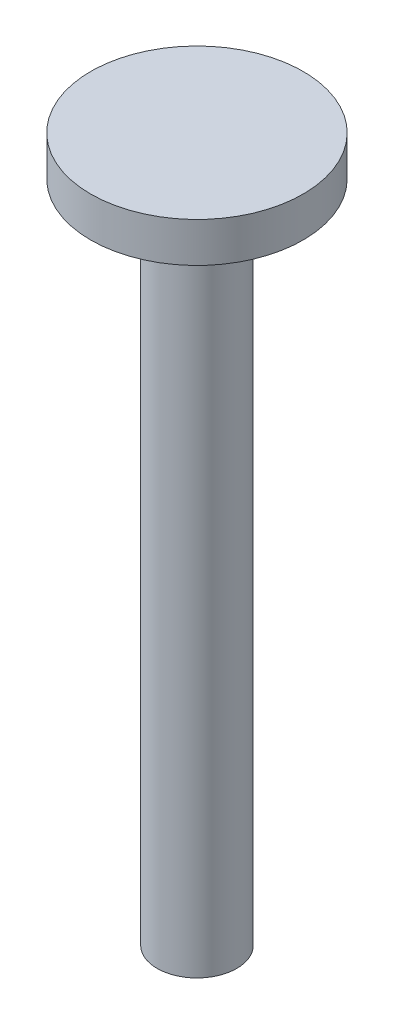
from build123d import *

# Parameters (mm, degrees)
SKETCH1_R           = 4
BOSS_EXTRUDE1_DEPTH = 1.5
SKETCH5_R           = 1.5
BOSS_EXTRUDE3_DEPTH = 25


with BuildPart() as part:
    # Sketch1 → Boss-Extrude1 (new body)
    with BuildSketch(Plane(origin=(0, 0, 0), x_dir=(1, 0, 0), z_dir=(0, 1, 0))):
        Circle(SKETCH1_R)
    extrude(amount=BOSS_EXTRUDE1_DEPTH)

    # Sketch5 → Boss-Extrude3 (add)
    with BuildSketch(Plane(origin=(0, 0, 0), x_dir=(-1, 0, 0), z_dir=(0, -1, 0))):
        Circle(SKETCH5_R)
    extrude(amount=BOSS_EXTRUDE3_DEPTH)


solid = part.part
